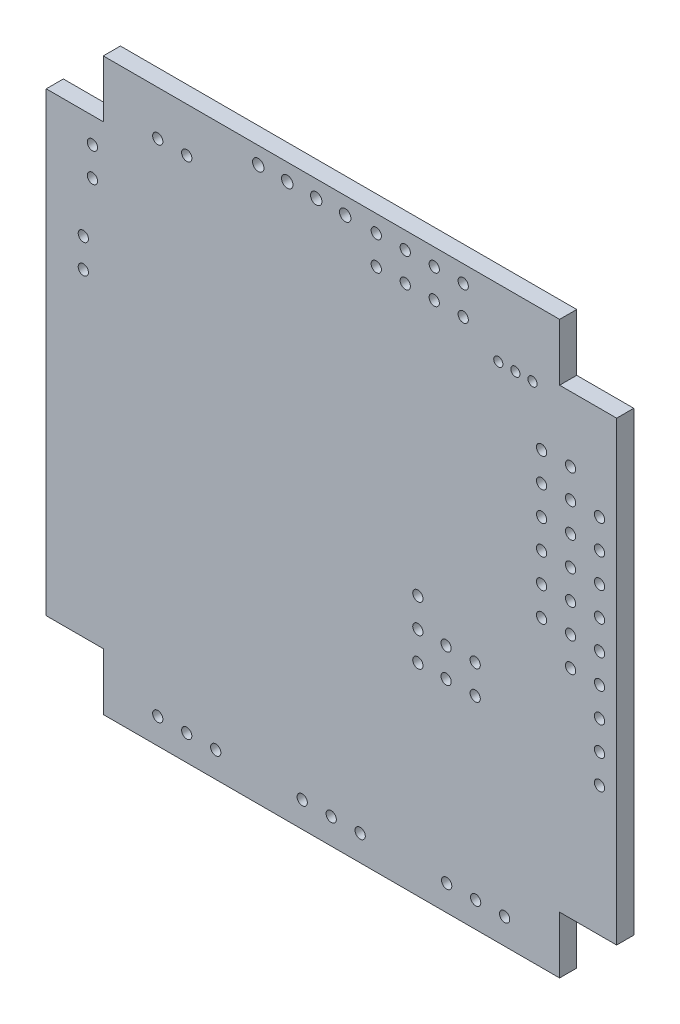
from build123d import *

# Parameters (mm, degrees)
SKETCH_3_R      = 0.4499991
SKETCH_3_R_2    = 0.3999992
SKETCH_3_R_3    = 0.499999
EXTRUDE_1_DEPTH = 1.5


with BuildPart() as part:
    # Эскиз3 → Бобышка-Вытянуть1 (new body)
    with BuildSketch(Plane.XY):
        Polygon((24.081237265, -17.758826004), (24.081237265, 22.241173056), (19.081237265, 22.241173056), (19.081237265, 27.241173056), (-20.918761795, 27.241173056), (-20.918761795, 22.241173056), (-25.918761795, 22.241173056), (-25.918761795, -17.758826004), (-20.918761795, -17.758826004), (-20.918761795, -22.758826004), (19.081237265, -22.758826004), (19.081237265, -17.758826004), align=None)
        with Locations((22.581258045, 1.241166636)):
            Circle(SKETCH_3_R, mode=Mode.SUBTRACT)
        with Locations((22.581258045, 3.791174236)):
            Circle(SKETCH_3_R, mode=Mode.SUBTRACT)
        with Locations((22.581258045, 6.341181836)):
            Circle(SKETCH_3_R, mode=Mode.SUBTRACT)
        with Locations((22.581258045, 8.891189436)):
            Circle(SKETCH_3_R, mode=Mode.SUBTRACT)
        with Locations((22.581258045, 11.441197036)):
            Circle(SKETCH_3_R, mode=Mode.SUBTRACT)
        with Locations((22.581258045, 13.991204636)):
            Circle(SKETCH_3_R, mode=Mode.SUBTRACT)
        with Locations((17.501258045, 3.791174236)):
            Circle(SKETCH_3_R, mode=Mode.SUBTRACT)
        with Locations((17.501258045, 6.341181836)):
            Circle(SKETCH_3_R, mode=Mode.SUBTRACT)
        with Locations((17.501258045, 8.891189436)):
            Circle(SKETCH_3_R, mode=Mode.SUBTRACT)
        with Locations((17.501258045, 11.441197036)):
            Circle(SKETCH_3_R, mode=Mode.SUBTRACT)
        with Locations((17.501258045, 13.991204636)):
            Circle(SKETCH_3_R, mode=Mode.SUBTRACT)
        with Locations((17.501258045, 16.541212236)):
            Circle(SKETCH_3_R, mode=Mode.SUBTRACT)
        with Locations((20.041258045, 16.541212236)):
            Circle(SKETCH_3_R, mode=Mode.SUBTRACT)
        with Locations((20.041258045, 13.991204636)):
            Circle(SKETCH_3_R, mode=Mode.SUBTRACT)
        with Locations((20.041258045, 11.441197036)):
            Circle(SKETCH_3_R, mode=Mode.SUBTRACT)
        with Locations((20.041258045, 8.891189436)):
            Circle(SKETCH_3_R, mode=Mode.SUBTRACT)
        with Locations((20.041258045, 6.341181836)):
            Circle(SKETCH_3_R, mode=Mode.SUBTRACT)
        with Locations((20.041258045, 3.791174236)):
            Circle(SKETCH_3_R, mode=Mode.SUBTRACT)
        with Locations((20.041258045, 1.241166636)):
            Circle(SKETCH_3_R, mode=Mode.SUBTRACT)
        with Locations((22.581235185, -6.388825724)):
            Circle(SKETCH_3_R, mode=Mode.SUBTRACT)
        with Locations((22.581235185, -3.848825724)):
            Circle(SKETCH_3_R, mode=Mode.SUBTRACT)
        with Locations((22.581235185, -1.308825724)):
            Circle(SKETCH_3_R, mode=Mode.SUBTRACT)
        with Locations((3.011236225, 25.741170976)):
            Circle(SKETCH_3_R, mode=Mode.SUBTRACT)
        with Locations((5.551236225, 23.201170976)):
            Circle(SKETCH_3_R, mode=Mode.SUBTRACT)
        with Locations((5.551236225, 25.741170976)):
            Circle(SKETCH_3_R, mode=Mode.SUBTRACT)
        with Locations((8.091236225, 23.201170976)):
            Circle(SKETCH_3_R, mode=Mode.SUBTRACT)
        with Locations((8.091236225, 25.741170976)):
            Circle(SKETCH_3_R, mode=Mode.SUBTRACT)
        with Locations((10.631236225, 25.741170976)):
            Circle(SKETCH_3_R, mode=Mode.SUBTRACT)
        with Locations((10.631236225, 23.201170976)):
            Circle(SKETCH_3_R, mode=Mode.SUBTRACT)
        with Locations((13.706236425, 21.341172156)):
            Circle(SKETCH_3_R_2, mode=Mode.SUBTRACT)
        with Locations((15.206235965, 21.341172156)):
            Circle(SKETCH_3_R_2, mode=Mode.SUBTRACT)
        with Locations((16.706235505, 21.341172156)):
            Circle(SKETCH_3_R_2, mode=Mode.SUBTRACT)
        with Locations((6.656270845, 0.041156336)):
            Circle(SKETCH_3_R, mode=Mode.SUBTRACT)
        with Locations((6.656270845, -5.038843664)):
            Circle(SKETCH_3_R, mode=Mode.SUBTRACT)
        with Locations((6.656270845, -2.498843664)):
            Circle(SKETCH_3_R, mode=Mode.SUBTRACT)
        with Locations((9.131325585, -2.498843664)):
            Circle(SKETCH_3_R, mode=Mode.SUBTRACT)
        with Locations((9.131325585, -5.038843664)):
            Circle(SKETCH_3_R, mode=Mode.SUBTRACT)
        with Locations((11.681361125, -2.498843664)):
            Circle(SKETCH_3_R, mode=Mode.SUBTRACT)
        with Locations((14.261284845, -20.508802564)):
            Circle(SKETCH_3_R, mode=Mode.SUBTRACT)
        with Locations((11.721284845, -20.508802564)):
            Circle(SKETCH_3_R, mode=Mode.SUBTRACT)
        with Locations((9.181284845, -20.508802564)):
            Circle(SKETCH_3_R, mode=Mode.SUBTRACT)
        with Locations((1.598775245, -20.508802564)):
            Circle(SKETCH_3_R, mode=Mode.SUBTRACT)
        with Locations((-0.941224755, -20.508802564)):
            Circle(SKETCH_3_R, mode=Mode.SUBTRACT)
        with Locations((-3.481224755, -20.508802564)):
            Circle(SKETCH_3_R, mode=Mode.SUBTRACT)
        with Locations((-11.063734355, -20.508802564)):
            Circle(SKETCH_3_R, mode=Mode.SUBTRACT)
        with Locations((-13.603734355, -20.508802564)):
            Circle(SKETCH_3_R, mode=Mode.SUBTRACT)
        with Locations((-16.143734355, -20.508802564)):
            Circle(SKETCH_3_R, mode=Mode.SUBTRACT)
        with Locations((-22.668758135, 10.141171696)):
            Circle(SKETCH_3_R, mode=Mode.SUBTRACT)
        with Locations((-22.668758135, 12.681171696)):
            Circle(SKETCH_3_R, mode=Mode.SUBTRACT)
        with Locations((-7.333782455, 25.756172216)):
            Circle(SKETCH_3_R_3, mode=Mode.SUBTRACT)
        with Locations((-4.793782455, 25.756172216)):
            Circle(SKETCH_3_R_3, mode=Mode.SUBTRACT)
        with Locations((-2.253782455, 25.756172216)):
            Circle(SKETCH_3_R_3, mode=Mode.SUBTRACT)
        with Locations((0.286217545, 25.756172216)):
            Circle(SKETCH_3_R_3, mode=Mode.SUBTRACT)
        with Locations((3.011236225, 23.201170976)):
            Circle(SKETCH_3_R, mode=Mode.SUBTRACT)
        with Locations((11.681361125, -5.038843664)):
            Circle(SKETCH_3_R, mode=Mode.SUBTRACT)
        with Locations((-21.868764815, 17.476170996)):
            Circle(SKETCH_3_R, mode=Mode.SUBTRACT)
        with Locations((-21.868764815, 20.016170996)):
            Circle(SKETCH_3_R, mode=Mode.SUBTRACT)
        with Locations((-16.143764835, 23.341173236)):
            Circle(SKETCH_3_R, mode=Mode.SUBTRACT)
        with Locations((-13.603764835, 23.341173236)):
            Circle(SKETCH_3_R, mode=Mode.SUBTRACT)
    extrude(amount=EXTRUDE_1_DEPTH)


solid = part.part
